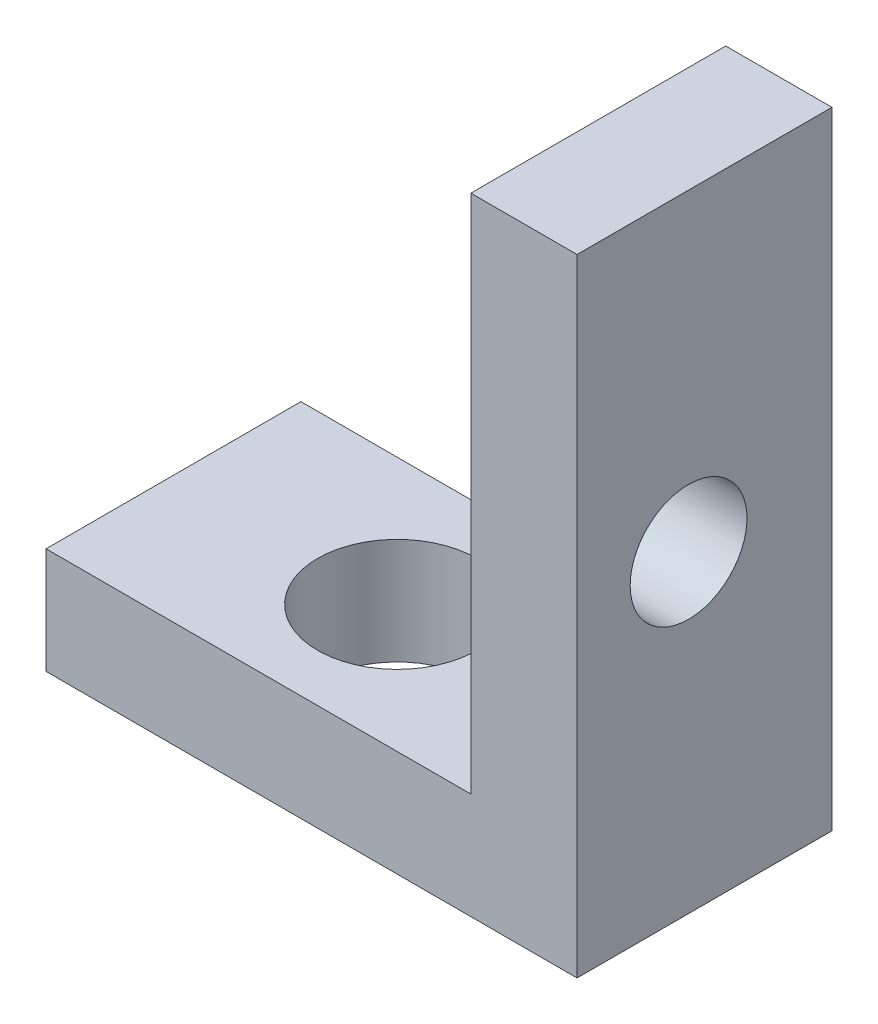
from build123d import *

# Parameters (mm, degrees)
BOSS_EXTRUDE1_DEPTH = 4.8
CUT_EXTRUDE1_REACH  = 4
SKETCH2_R           = 1.1
CUT_EXTRUDE2_REACH  = 4
SKETCH3_R           = 1.5


with BuildPart() as part:
    # Sketch1 → Boss-Extrude1 (new body)
    with BuildSketch(Plane.XY):
        Polygon((0, 0), (0, 11.8), (-2, 11.8), (-2, 2), (-10, 2), (-10, 0), align=None)
    extrude(amount=BOSS_EXTRUDE1_DEPTH)

    # Sketch2 → Cut-Extrude1 (cut, up to next)
    with BuildSketch(Plane.ZY.offset(2), mode=Mode.PRIVATE) as cut_extrude1_sk1:
        with Locations((2.7, 5.9)):
            Circle(SKETCH2_R)
    cut_extrude1_tool1 = extrude(cut_extrude1_sk1.sketch, amount=-CUT_EXTRUDE1_REACH, mode=Mode.PRIVATE) & part.part
    add(cut_extrude1_tool1.solids().sort_by_distance((-2, 5.9, 2.7))[0], mode=Mode.SUBTRACT)

    # Sketch3 → Cut-Extrude2 (cut, up to next)
    with BuildSketch(Plane(origin=(0, 2, 0), x_dir=(1, 0, 0), z_dir=(0, 1, 0)), mode=Mode.PRIVATE) as cut_extrude2_sk1:
        with Locations((-5.786663097, -2.4)):
            Circle(SKETCH3_R)
    cut_extrude2_tool1 = extrude(cut_extrude2_sk1.sketch, amount=-CUT_EXTRUDE2_REACH, mode=Mode.PRIVATE) & part.part
    add(cut_extrude2_tool1.solids().sort_by_distance((-5.786663, 2, 2.4))[0], mode=Mode.SUBTRACT)


solid = part.part
